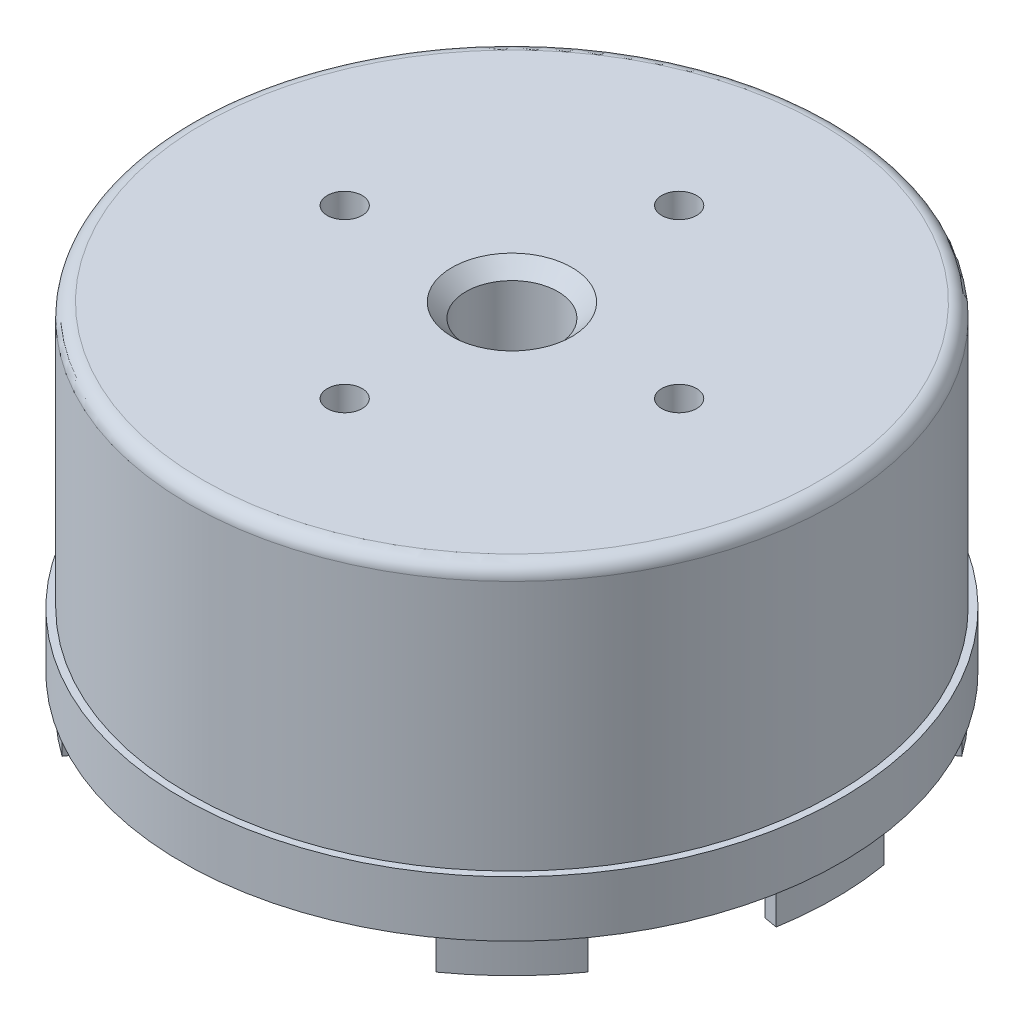
from build123d import *

# Parameters (mm, degrees)
SKETCH_1_R               = 23.15
EXTRUDE_1_DEPTH          = 19
CUT_EXTRUDE_1_DEPTH      = 38.85293912
CUT_EXTRUDE_1_DEPTH_BACK = 38.85293912
SKETCH_2_R               = 3.3
PATTERN_CIRCULAR_1_COUNT = 4
FILLET_1_R               = 1
SKETCH_6_R               = 23.65
EXTRUDE_2_DEPTH          = 0.5
SKETCH_7_R               = 23.65
SKETCH_7_R_2             = 23.15
EXTRUDE_1_2_DEPTH        = 3.5
EXTRUDE_5_DEPTH          = 6
PATTERN_CIRCULAR_3_COUNT = 8
SKETCH_18_R              = 3.3
CUT_EXTRUDE_2_DEPTH      = 39.466153954
SKETCH_19_R              = 6.3
SKETCH_19_R_2            = 3.3
EXTRUDE_6_DEPTH          = 4
CHAMFER_1_SIZE           = 1
FILLET_3_R               = 0.5
FILLET_4_R               = 0.5


with BuildPart() as part:
    # 草图1 → Extrude 1 (new body)
    with BuildSketch(Plane(origin=(0, 0, 0), x_dir=(1, 0, 0), z_dir=(0, 1, 0))):
        Circle(SKETCH_1_R)
    extrude(amount=EXTRUDE_1_DEPTH)

    # 草图5 → M3 螺纹孔1 (revolve, cut)
    with BuildSketch(Plane(origin=(-12, 19, 0), x_dir=(0, 0, 1), z_dir=(1, 0, 0))):
        Polygon((0, 0), (0, 4.751075774), (1.25, 4), (1.25, 0), align=None)
    hole_wizard_m3_1 = revolve(axis=Axis((-12, 25.35, 0), (0, -1, 0)), mode=Mode.SUBTRACT)

    # 草图2 → 切除-拉伸1 (cut, two sides: drawn at the far end of the back side and taken through both)
    with BuildSketch(Plane(origin=(0, 19, 0), x_dir=(1, 0, 0), z_dir=(0, 1, 0)).offset(-CUT_EXTRUDE_1_DEPTH_BACK)):
        Circle(SKETCH_2_R)
    extrude(amount=CUT_EXTRUDE_1_DEPTH + CUT_EXTRUDE_1_DEPTH_BACK, mode=Mode.SUBTRACT)

    # 阵列(圆周)1: M3 螺纹孔1 ×4 about axis
    pattern_circular_1_axis = Axis((0, 0, 0), (0, 1, 0))
    for i in range(1, PATTERN_CIRCULAR_1_COUNT):
        add(hole_wizard_m3_1.rotate(pattern_circular_1_axis, i * 360 / PATTERN_CIRCULAR_1_COUNT), mode=Mode.SUBTRACT)

    # 圆角1
    fillet_1_edges = [part.edges().sort_by_distance(p)[0] for p in [
        (-23.15, 19, 0),
    ]]
    fillet(fillet_1_edges, radius=FILLET_1_R)

    # 草图6 → 凸台-拉伸2 (add)
    with BuildSketch(Plane.XZ):
        Circle(SKETCH_6_R)
    extrude(amount=EXTRUDE_2_DEPTH)

    # 草图7 → Extrude 1 2 (add)
    with BuildSketch(Plane.XZ.offset(0.5)):
        Circle(SKETCH_7_R)
        Circle(SKETCH_7_R_2, mode=Mode.SUBTRACT)
    extrude(amount=EXTRUDE_1_2_DEPTH)

    # 草图8 → 凸台-拉伸5 (add)
    with BuildSketch(Plane.XZ.offset(0.5)):
        with BuildLine():
            Line((-21.839675903, 3.694733612), (-22.825665785, 3.861538741))
            ThreePointArc((-22.825665785, 3.861538741), (-23.15, 0), (-22.825665785, -3.861538741))
            Line((-22.825665785, -3.861538741), (-21.839675903, -3.694733612))
            ThreePointArc((-21.839675903, -3.694733612), (-20.969056247, -2.594652523), (-19.772134146, -1.862850316))
            ThreePointArc((-19.772134146, -1.862850316), (-18.5, 0), (-19.772134146, 1.862850316))
            ThreePointArc((-19.772134146, 1.862850316), (-20.969056247, 2.594652523), (-21.839675903, 3.694733612))
        make_face()
        with BuildLine():
            ThreePointArc((-13.409662832, 18.870703292), (-16.369521984, 16.369521984), (-18.870703292, 13.409662832))
            Line((-18.870703292, 13.409662832), (-18.055554121, 12.830411738))
            ThreePointArc((-18.055554121, 12.830411738), (-16.662058262, 12.992665473), (-15.298244224, 12.663776043))
            ThreePointArc((-15.298244224, 12.663776043), (-13.081475452, 13.081475452), (-12.663776043, 15.298244224))
            ThreePointArc((-12.663776043, 15.298244224), (-12.992665473, 16.662058262), (-12.830411738, 18.055554121))
            Line((-12.830411738, 18.055554121), (-13.409662832, 18.870703292))
        make_face()
        with BuildLine():
            Line((-18.055554121, -12.830411738), (-18.870703292, -13.409662832))
            ThreePointArc((-18.870703292, -13.409662832), (-16.369521984, -16.369521984), (-13.409662832, -18.870703292))
            Line((-13.409662832, -18.870703292), (-12.830411738, -18.055554121))
            ThreePointArc((-12.830411738, -18.055554121), (-12.992665473, -16.662058261), (-12.663776043, -15.298244224))
            ThreePointArc((-12.663776043, -15.298244224), (-13.081475452, -13.081475452), (-15.298244224, -12.663776043))
            ThreePointArc((-15.298244224, -12.663776043), (-16.662058261, -12.992665473), (-18.055554121, -12.830411738))
        make_face()
        with BuildLine():
            ThreePointArc((18.870703292, 13.409662832), (16.369521984, 16.369521984), (13.409662832, 18.870703292))
            Line((13.409662832, 18.870703292), (12.830411738, 18.055554121))
            ThreePointArc((12.830411738, 18.055554121), (12.992665473, 16.662058262), (12.663776043, 15.298244224))
            ThreePointArc((12.663776043, 15.298244224), (13.081475452, 13.081475452), (15.298244224, 12.663776043))
            ThreePointArc((15.298244224, 12.663776043), (16.662058261, 12.992665473), (18.055554121, 12.830411738))
            Line((18.055554121, 12.830411738), (18.870703292, 13.409662832))
        make_face()
        with BuildLine():
            Line((12.830411738, -18.055554121), (13.409662832, -18.870703292))
            ThreePointArc((13.409662832, -18.870703292), (16.369521984, -16.369521984), (18.870703292, -13.409662832))
            Line((18.870703292, -13.409662832), (18.055554121, -12.830411738))
            ThreePointArc((18.055554121, -12.830411738), (16.662058262, -12.992665473), (15.298244224, -12.663776043))
            ThreePointArc((15.298244224, -12.663776043), (13.081475452, -13.081475452), (12.663776043, -15.298244224))
            ThreePointArc((12.663776043, -15.298244224), (12.992665473, -16.662058261), (12.830411738, -18.055554121))
        make_face()
        with BuildLine():
            ThreePointArc((22.825665785, -3.861538741), (23.15, 0), (22.825665785, 3.861538741))
            Line((22.825665785, 3.861538741), (21.839675903, 3.694733612))
            ThreePointArc((21.839675903, 3.694733612), (20.969056247, 2.594652523), (19.772134146, 1.862850316))
            ThreePointArc((19.772134146, 1.862850316), (18.5, 0), (19.772134146, -1.862850316))
            ThreePointArc((19.772134146, -1.862850316), (20.969056247, -2.594652523), (21.839675903, -3.694733612))
            Line((21.839675903, -3.694733612), (22.825665785, -3.861538741))
        make_face()
    extrude(amount=EXTRUDE_5_DEPTH)

    # 草图17 → M2 螺纹孔1 (revolve, cut)
    with BuildSketch(Plane(origin=(-20.5, -6.5, 0), x_dir=(0, 0, -1), z_dir=(1, 0, 0))):
        Polygon((0, 0), (0, 5.680688495), (0.8, 5.2), (0.8, 0), align=None)
    hole_wizard_m2_1 = revolve(axis=Axis((-20.5, -12.85, 0), (0, 1, 0)), mode=Mode.SUBTRACT)

    # 阵列(圆周)3: M2 螺纹孔1 ×8 about axis, 1 skipped
    pattern_circular_3_axis = Axis((0, 0, 0), (0, 1, 0))
    add([hole_wizard_m2_1.rotate(pattern_circular_3_axis, i * 360 / PATTERN_CIRCULAR_3_COUNT) for i in range(1, PATTERN_CIRCULAR_3_COUNT) if i not in (2,)], mode=Mode.SUBTRACT)

    # 草图18 → 切除-拉伸2 (cut, through all)
    with BuildSketch(Plane(origin=(0, 0, 0), x_dir=(1, 0, 0), z_dir=(0, 1, 0))):
        Circle(SKETCH_18_R)
    extrude(amount=-CUT_EXTRUDE_2_DEPTH, mode=Mode.SUBTRACT)

    # 草图19 → 凸台-拉伸6 (add)
    with BuildSketch(Plane.XZ.offset(0.5)):
        Circle(SKETCH_19_R)
        Circle(SKETCH_19_R_2, mode=Mode.SUBTRACT)
    extrude(amount=EXTRUDE_6_DEPTH)

    # 倒角1
    chamfer_1_edges = [part.edges().sort_by_distance(p)[0] for p in [
        (-3.3, 19, 0),
    ]]
    chamfer(chamfer_1_edges, length=CHAMFER_1_SIZE)

    # 圆角3
    fillet_3_edges = [part.edges().sort_by_distance(p)[0] for p in [
        (-6.3, -4.5, 0),
    ]]
    fillet(fillet_3_edges, radius=FILLET_3_R)

    # 圆角4
    fillet_4_edges = [part.edges().sort_by_distance(p)[0] for p in [
        (-3.3, -4.5, 0),
    ]]
    fillet(fillet_4_edges, radius=FILLET_4_R)


solid = part.part
